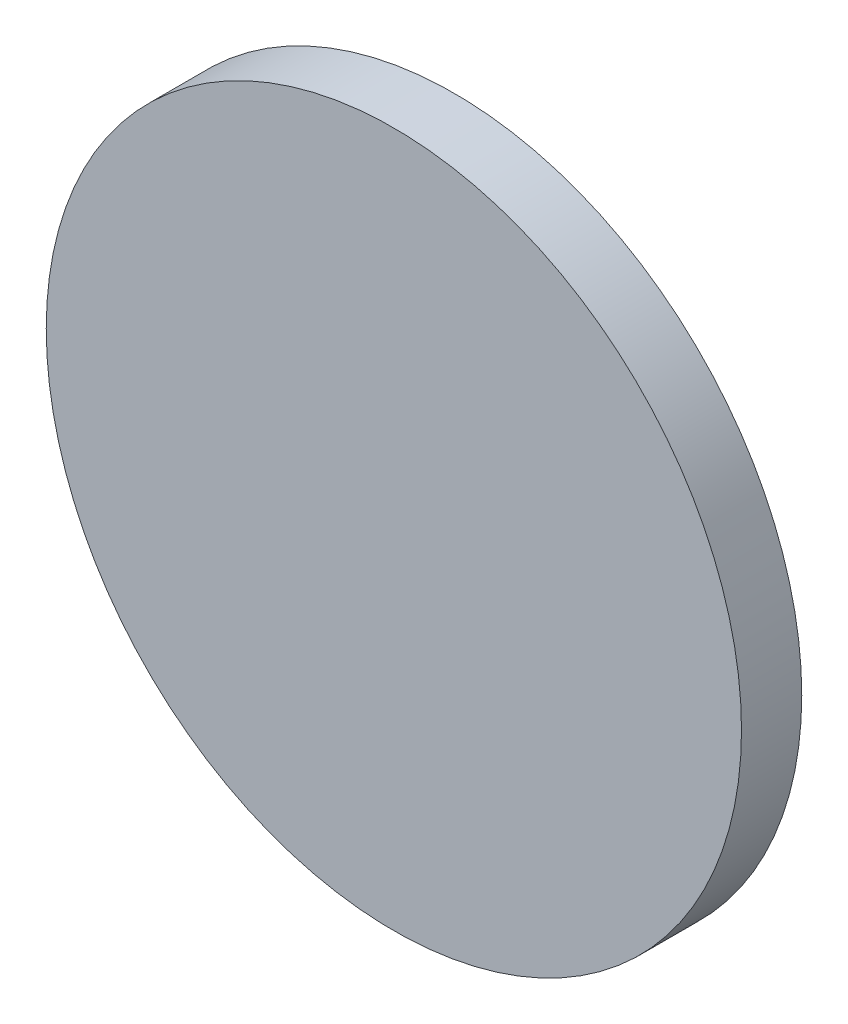
from build123d import *

# Parameters (mm, degrees)
SKETCH1_R           = 75
BOSS_EXTRUDE1_DEPTH = 13


with BuildPart() as part:
    # Sketch1 → Boss-Extrude1 (new body)
    with BuildSketch(Plane.XY):
        Circle(SKETCH1_R)
    extrude(amount=BOSS_EXTRUDE1_DEPTH)


solid = part.part
